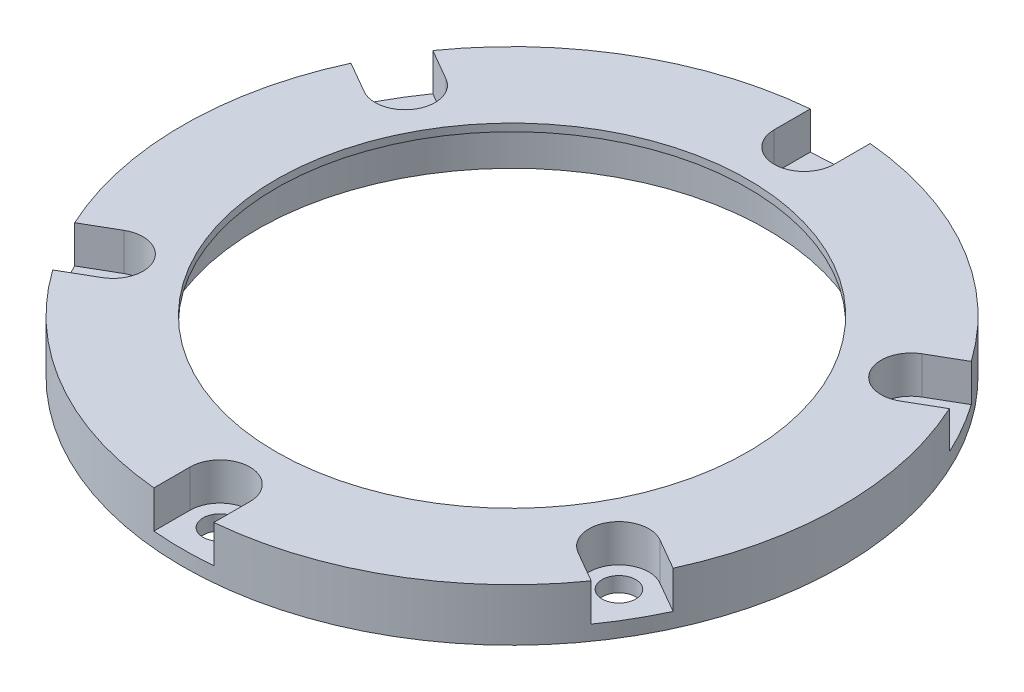
from build123d import *

# Parameters (mm, degrees)
SKETCH_1_R                   = 44
SKETCH_1_R_2                 = 34
EXTRUDE_1_DEPTH              = 6
SKETCH_2_R                   = 44
SKETCH_2_R_2                 = 31.5
EXTRUDE_2_DEPTH              = 1
HOLE_WIZARD_M4_1_D           = 4.5
HOLE_WIZARD_M4_1_CBORE_D     = 8
HOLE_WIZARD_M4_1_CBORE_DEPTH = 5
PATTERN_CIRCULAR_1_COUNT     = 6
CUT_EXTRUDE_1_DEPTH          = 5
PATTERN_CIRCULAR_2_COUNT     = 6


with BuildPart() as part:
    # 스케치1 → 보스-돌출1 (new body)
    with BuildSketch(Plane(origin=(0, 0, 0), x_dir=(1, 0, 0), z_dir=(0, 1, 0))):
        Circle(SKETCH_1_R)
        Circle(SKETCH_1_R_2, mode=Mode.SUBTRACT)
    extrude(amount=EXTRUDE_1_DEPTH)

    # 스케치2 → 보스-돌출2 (add)
    with BuildSketch(Plane(origin=(0, 6, 0), x_dir=(1, 0, 0), z_dir=(0, 1, 0))):
        Circle(SKETCH_2_R)
        Circle(SKETCH_2_R_2, mode=Mode.SUBTRACT)
    extrude(amount=EXTRUDE_2_DEPTH)

    # M4 육각 소켓 머리 캡 나사용 카운터보어1 (through all)
    with Locations(Plane(origin=(0, 7, 0), x_dir=(1, 0, 0), z_dir=(0, 1, 0))):
        with Locations((0, 39)):
            hole_wizard_m4_1 = CounterBoreHole(HOLE_WIZARD_M4_1_D / 2, HOLE_WIZARD_M4_1_CBORE_D / 2, HOLE_WIZARD_M4_1_CBORE_DEPTH)

    # 원형 패턴1: M4 육각 소켓 머리 캡 나사용 카운터보어1 ×6 about axis
    pattern_circular_1_axis = Axis((0, 0, 0), (0, 1, 0))
    for i in range(1, PATTERN_CIRCULAR_1_COUNT):
        add(hole_wizard_m4_1.rotate(pattern_circular_1_axis, i * 360 / PATTERN_CIRCULAR_1_COUNT), mode=Mode.SUBTRACT)

    # 스케치7 → 컷-돌출1 (cut, symmetric)
    with BuildSketch(Plane(origin=(0, 7, 0), x_dir=(1, 0, 0), z_dir=(0, 1, 0))):
        with BuildLine():
            Line((-4, 39), (-4, 44))
            Line((-4, 44), (4, 44))
            Line((4, 44), (4, 39))
            ThreePointArc((4, 39), (0, 43), (-4, 39))
        make_face()
    cut_extrude_1 = extrude(amount=CUT_EXTRUDE_1_DEPTH, both=True, mode=Mode.SUBTRACT)

    # 원형 패턴2: 컷-돌출1 ×6 about axis
    pattern_circular_2_axis = Axis((0, 0, 0), (0, 1, 0))
    for i in range(1, PATTERN_CIRCULAR_2_COUNT):
        add(cut_extrude_1.rotate(pattern_circular_2_axis, i * 360 / PATTERN_CIRCULAR_2_COUNT), mode=Mode.SUBTRACT)


solid = part.part
